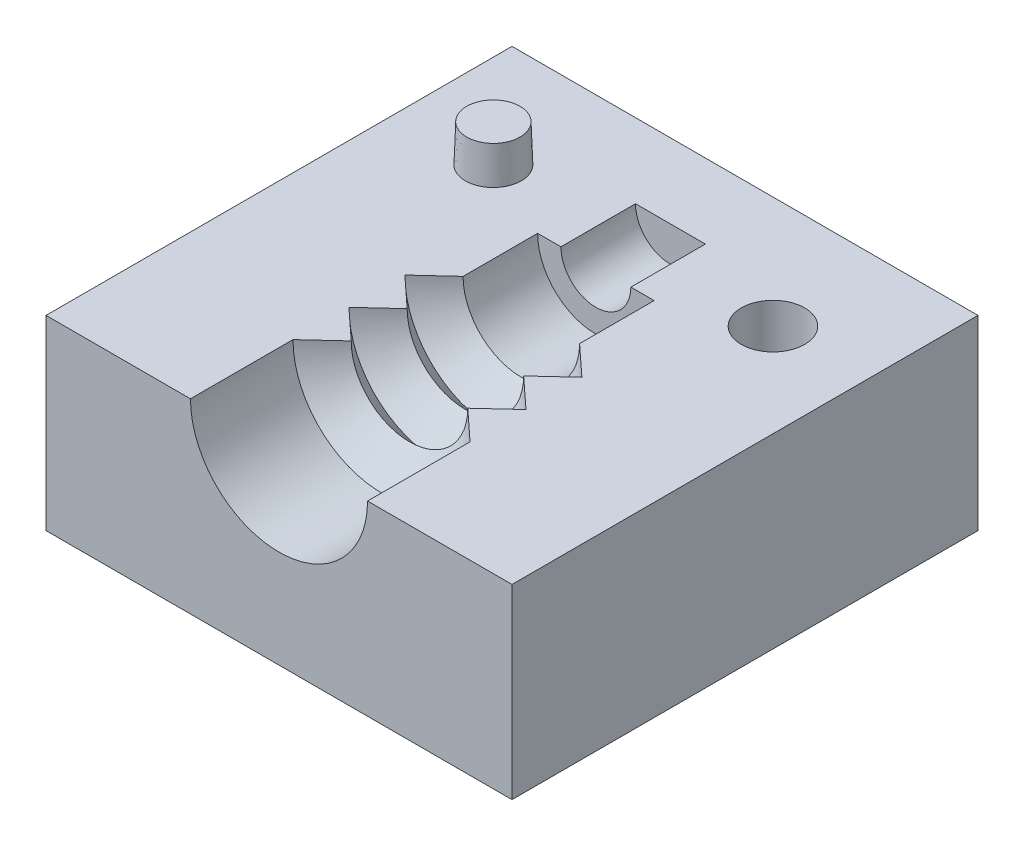
from build123d import *

# Parameters (mm, degrees)
SKETCH2_W           = 25
SKETCH2_H           = 25
BOSS_EXTRUDE1_DEPTH = 10
SKETCH4_R           = 1.5
BOSS_EXTRUDE2_DEPTH = 2
BOSS_EXTRUDE2_TAPER = 2
SKETCH5_R           = 1.7
CUT_EXTRUDE1_DEPTH  = 2.5


with BuildPart() as part:
    # Sketch2 → Boss-Extrude1 (new body)
    with BuildSketch(Plane(origin=(0, 0, 0), x_dir=(1, 0, 0), z_dir=(0, 1, 0))):
        Rectangle(SKETCH2_W, SKETCH2_H)
    extrude(amount=BOSS_EXTRUDE1_DEPTH)

    # Sketch3 → Cut-Revolve1 (revolve, cut)
    with BuildSketch(Plane(origin=(0, 10, 0), x_dir=(1, 0, 0), z_dir=(0, 1, 0))):
        Polygon((0, -12.5), (4.75, -12.5), (4.75, -7), (3.125, -5.5), (4.75, -4), (3.125, -2.5), (4.75, -1), (3.125, 0.5), (3.125, 4.5), (1.875, 4.5), (1.875, 8.5), (0, 8.5), align=None)
    revolve(axis=Axis((0, 10, -12.5), (0, 0, 1)), mode=Mode.SUBTRACT)

    # Sketch4 → Boss-Extrude2 (add)
    with BuildSketch(Plane(origin=(0, 10, 0), x_dir=(1, 0, 0), z_dir=(0, 1, 0))):
        with Locations((-7.5, 6.5)):
            Circle(SKETCH4_R)
    extrude(amount=BOSS_EXTRUDE2_DEPTH, taper=BOSS_EXTRUDE2_TAPER)

    # Sketch5 → Cut-Extrude1 (cut)
    with BuildSketch(Plane(origin=(0, 10, 0), x_dir=(1, 0, 0), z_dir=(0, 1, 0))):
        with Locations((7.5, 6.5)):
            Circle(SKETCH5_R)
    extrude(amount=-CUT_EXTRUDE1_DEPTH, mode=Mode.SUBTRACT)


solid = part.part
